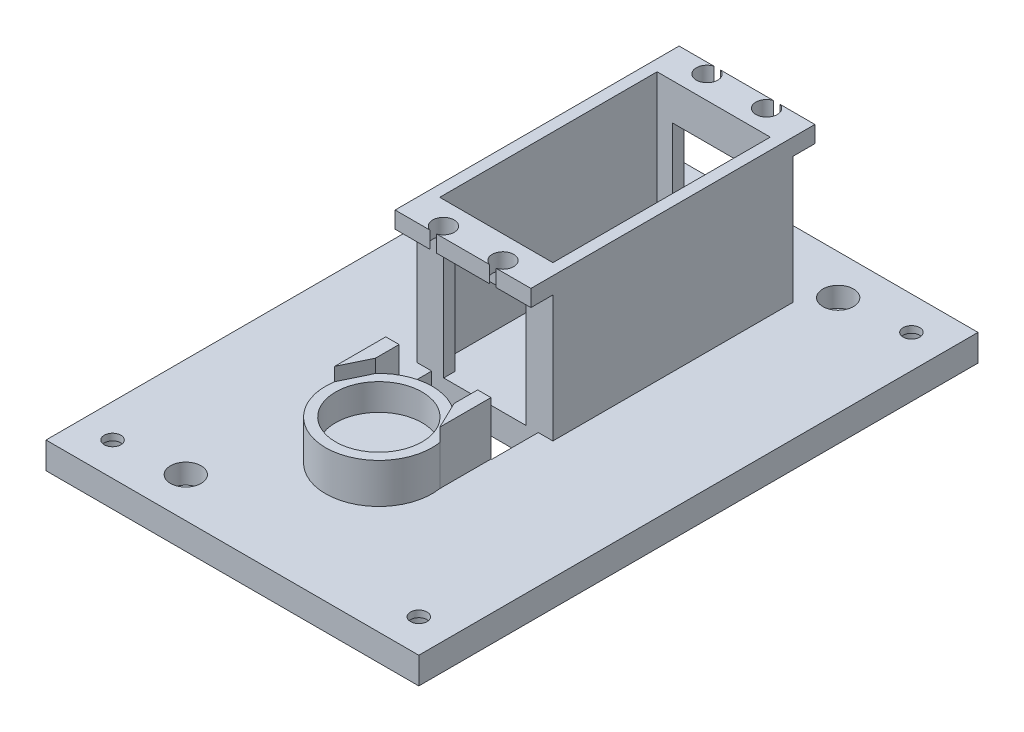
from build123d import *

# Parameters (mm, degrees)
SKETCH1_W           = 71.12
SKETCH1_H           = 106.68
BOSS_EXTRUDE1_DEPTH = 5.08
SKETCH3_W           = 25.908
SKETCH3_H           = 45.7962
SKETCH3_W_2         = 21.59
SKETCH3_H_2         = 41.4782
BOSS_EXTRUDE2_DEPTH = 24.13
SKETCH4_W           = 25.908
SKETCH4_H           = 54.1782
SKETCH4_W_2         = 21.59
SKETCH4_H_2         = 41.4782
BOSS_EXTRUDE3_DEPTH = 3.175
SKETCH5_R           = 2.04968221
CUT_EXTRUDE1_DEPTH  = 3.175
SKETCH7_W           = 15.748
SKETCH7_H           = 20.32
CUT_EXTRUDE3_DEPTH  = 45.7962
SKETCH8_R           = 10.16
BOSS_EXTRUDE4_DEPTH = 7.62
SKETCH9_R           = 8.255
CUT_EXTRUDE4_DEPTH  = 5.08
SKETCH10_W          = 20.32
SKETCH10_H          = 8.89
CUT_EXTRUDE5_DEPTH  = 6.08
SKETCH11_R          = 1.5875
CUT_EXTRUDE6_DEPTH  = 6.08
SKETCH15_R          = 2.921
CUT_EXTRUDE7_DEPTH  = 3.81
SKETCH16_R          = 2.921
CUT_EXTRUDE8_DEPTH  = 3.81
SKETCH17_R          = 1.5875
CUT_EXTRUDE9_DEPTH  = 33.385
BOSS_EXTRUDE5_DEPTH = 10.16


with BuildPart() as part:
    # Sketch1 → Boss-Extrude1 (new body)
    with BuildSketch(Plane(origin=(56.401870569, 0, 2.613156724), x_dir=(1, 0, 0), z_dir=(0, 1, 0))):
        with Locations((-28.531301018, -3.803535099)):
            Rectangle(SKETCH1_W, SKETCH1_H)
    extrude(amount=BOSS_EXTRUDE1_DEPTH)

    # Sketch3 → Boss-Extrude2 (add)
    with BuildSketch(Plane(origin=(56.401870569, 5.08, 2.613156724), x_dir=(1, 0, 0), z_dir=(0, 1, 0))):
        with Locations((-28.531301018, 13.938364901)):
            Rectangle(SKETCH3_W, SKETCH3_H)
        with Locations((-28.531301018, 13.938364901)):
            Rectangle(SKETCH3_W_2, SKETCH3_H_2, mode=Mode.SUBTRACT)
    extrude(amount=BOSS_EXTRUDE2_DEPTH)

    # Sketch4 → Boss-Extrude3 (add)
    with BuildSketch(Plane(origin=(0, 29.21, 0), x_dir=(1, 0, 0), z_dir=(0, 1, 0))):
        with Locations((27.87056955, 11.325208176)):
            Rectangle(SKETCH4_W, SKETCH4_H)
        with Locations((27.87056955, 11.325208176)):
            Rectangle(SKETCH4_W_2, SKETCH4_H_2, mode=Mode.SUBTRACT)
    extrude(amount=BOSS_EXTRUDE3_DEPTH)

    # Sketch5 → Cut-Extrude1 (cut)
    with BuildSketch(Plane(origin=(0, 32.385, 0), x_dir=(1, 0, 0), z_dir=(0, 1, 0))):
        with Locations((22.19366955, 36.471208176)):
            Circle(SKETCH5_R)
        with Locations((33.54746955, 36.471208176)):
            Circle(SKETCH5_R)
        with Locations((22.19366955, -13.820791824)):
            Circle(SKETCH5_R)
        with Locations((33.54746955, -13.820791824)):
            Circle(SKETCH5_R)
    extrude(amount=-CUT_EXTRUDE1_DEPTH, mode=Mode.SUBTRACT)

    # Sketch7 → Cut-Extrude3 (cut)
    with BuildSketch(Plane(origin=(0, 0, -34.223308176), x_dir=(-1, 0, 0), z_dir=(0, 0, -1))):
        with Locations((-27.87056955, 15.24)):
            Rectangle(SKETCH7_W, SKETCH7_H)
    extrude(amount=-CUT_EXTRUDE3_DEPTH, mode=Mode.SUBTRACT)

    # Sketch8 → Boss-Extrude4 (add)
    with BuildSketch(Plane(origin=(0, 5.08, 0), x_dir=(1, 0, 0), z_dir=(0, 1, 0))):
        with Locations((27.87056955, -31.816691824)):
            Circle(SKETCH8_R)
    extrude(amount=BOSS_EXTRUDE4_DEPTH)

    # Sketch9 → Cut-Extrude4 (cut)
    with BuildSketch(Plane(origin=(0, 12.7, 0), x_dir=(1, 0, 0), z_dir=(0, 1, 0))):
        with Locations((27.87056955, -31.816691824)):
            Circle(SKETCH9_R)
    extrude(amount=-CUT_EXTRUDE4_DEPTH, mode=Mode.SUBTRACT)

    # Sketch10 → Cut-Extrude5 (cut, through all)
    with BuildSketch(Plane(origin=(0, 5.08, 0), x_dir=(1, 0, 0), z_dir=(0, 1, 0))):
        with Locations((27.87056955, -16.017891824)):
            Rectangle(SKETCH10_W, SKETCH10_H)
    extrude(amount=-CUT_EXTRUDE5_DEPTH, mode=Mode.SUBTRACT)

    # Sketch11 → Cut-Extrude6 (cut, through all)
    with BuildSketch(Plane(origin=(0, 5.08, 0), x_dir=(1, 0, 0), z_dir=(0, 1, 0))):
        with Locations((44.38056955, 39.303308176)):
            Circle(SKETCH11_R)
        with Locations((11.36056955, -52.136691824)):
            Circle(SKETCH11_R)
    extrude(amount=-CUT_EXTRUDE6_DEPTH, mode=Mode.SUBTRACT)

    # Sketch15 → Cut-Extrude7 (cut)
    with BuildSketch(Plane(origin=(0, 5.08, 0), x_dir=(1, 0, 0), z_dir=(0, 1, 0))):
        with Locations((11.36056955, -52.136691824)):
            Circle(SKETCH15_R)
        with Locations((44.38056955, 39.303308176)):
            Circle(SKETCH15_R)
    extrude(amount=-CUT_EXTRUDE7_DEPTH, mode=Mode.SUBTRACT)

    # Sketch16 → Cut-Extrude8 (cut)
    with BuildSketch(Plane.XZ):
        with Locations((-1.33943045, 53.406691824)):
            Circle(SKETCH16_R)
        with Locations((57.08056955, 53.406691824)):
            Circle(SKETCH16_R)
        with Locations((57.08056955, -40.573308176)):
            Circle(SKETCH16_R)
        with Locations((-1.33943045, -40.573308176)):
            Circle(SKETCH16_R)
    extrude(amount=-CUT_EXTRUDE8_DEPTH, mode=Mode.SUBTRACT)

    # Sketch17 → Cut-Extrude9 (cut, through all)
    with BuildSketch(Plane.XZ):
        with Locations((-1.33943045, 53.406691824)):
            Circle(SKETCH17_R)
        with Locations((57.08056955, 53.406691824)):
            Circle(SKETCH17_R)
        with Locations((57.08056955, -40.573308176)):
            Circle(SKETCH17_R)
        with Locations((-1.33943045, -40.573308176)):
            Circle(SKETCH17_R)
    extrude(amount=-CUT_EXTRUDE9_DEPTH, mode=Mode.SUBTRACT)

    # Sketch23 → Boss-Extrude5 (add)
    with BuildSketch(Plane(origin=(0, 5.08, 0), x_dir=(1, 0, 0), z_dir=(0, 1, 0))):
        Polygon((20.37756955, -20.462891824), (17.83756955, -20.462891824), (17.83756955, -30.215282757), (20.37756955, -24.955164953), align=None)
        Polygon((35.36356955, -20.462891824), (37.90356955, -20.462891824), (37.90356955, -30.215282757), (35.36356955, -24.955164953), align=None)
    extrude(amount=BOSS_EXTRUDE5_DEPTH)


solid = part.part
